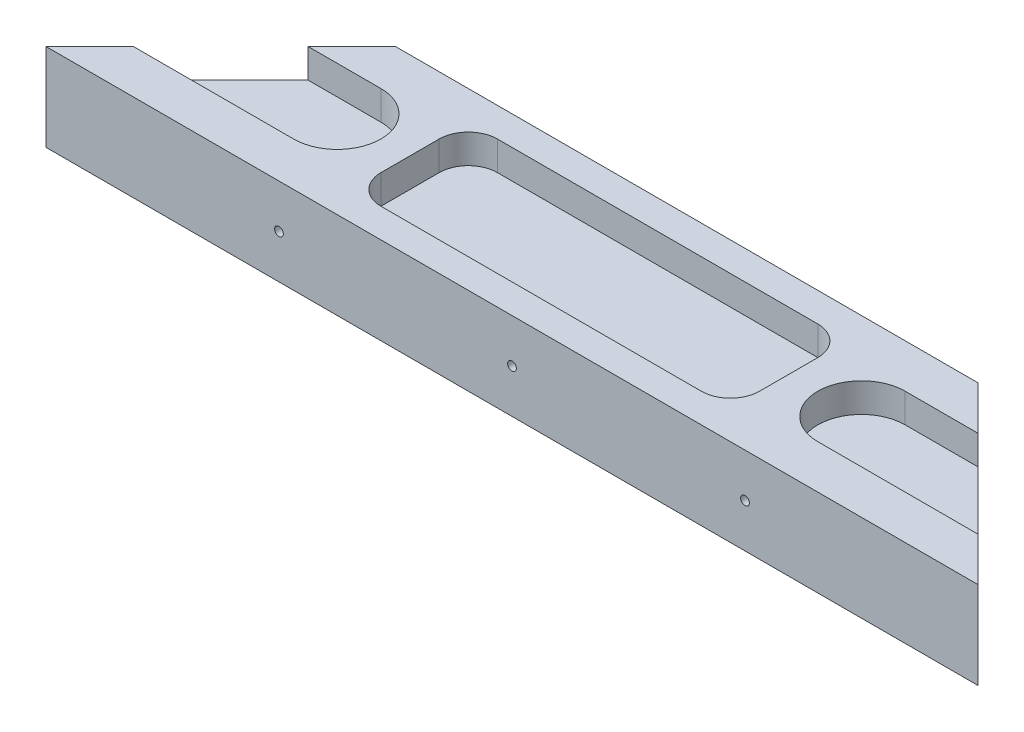
from build123d import *

# Parameters (mm, degrees)
BOSS_EXTRUDE1_DEPTH = 15
CUT_EXTRUDE1_DEPTH  = 5
SKETCH3_R           = 0.75
CUT_EXTRUDE2_DEPTH  = 30
CUT_EXTRUDE3_DEPTH  = 5


with BuildPart() as part:
    # Sketch1 → Boss-Extrude1 (new body)
    with BuildSketch(Plane(origin=(0, 0, 0), x_dir=(1, 0, 0), z_dir=(0, 1, 0))):
        Polygon((0, 0), (160, 0), (130, 30), (30, 30), align=None)
    extrude(amount=BOSS_EXTRUDE1_DEPTH)

    # Sketch2 → Cut-Extrude1 (cut)
    with BuildSketch(Plane(origin=(0, 15, 0), x_dir=(1, 0, 0), z_dir=(0, 1, 0))):
        with BuildLine():
            Line((-5, 22.5), (35, 22.5))
            ThreePointArc((35, 22.5), (42.5, 15), (35, 7.5))
            Line((35, 7.5), (-5, 7.5))
            ThreePointArc((-5, 7.5), (-12.5, 15), (-5, 22.5))
        make_face()
        with BuildLine():
            Line((165, 22.5), (125, 22.5))
            ThreePointArc((125, 22.5), (117.5, 15), (125, 7.5))
            Line((125, 7.5), (165, 7.5))
            ThreePointArc((165, 7.5), (172.5, 15), (165, 22.5))
        make_face()
    extrude(amount=-CUT_EXTRUDE1_DEPTH, mode=Mode.SUBTRACT)

    # Sketch3 → Cut-Extrude2 (cut)
    with BuildSketch(Plane.XY):
        with Locations((80, 7.5)):
            Circle(SKETCH3_R)
        with Locations((40, 7.5)):
            Circle(SKETCH3_R)
        with Locations((120, 7.5)):
            Circle(SKETCH3_R)
    extrude(amount=-CUT_EXTRUDE2_DEPTH, mode=Mode.SUBTRACT)

    # Sketch4 → Cut-Extrude3 (cut)
    with BuildSketch(Plane(origin=(0, 15, 0), x_dir=(1, 0, 0), z_dir=(0, 1, 0))):
        with BuildLine():
            Line((52.5, 25), (107.5, 25))
            ThreePointArc((107.5, 25), (111.035533906, 23.535533906), (112.5, 20))
            Line((112.5, 20), (112.5, 10))
            ThreePointArc((112.5, 10), (111.035533906, 6.464466094), (107.5, 5))
            Line((107.5, 5), (52.5, 5))
            ThreePointArc((52.5, 5), (48.964466094, 6.464466094), (47.5, 10))
            Line((47.5, 10), (47.5, 20))
            ThreePointArc((47.5, 20), (48.964466094, 23.535533906), (52.5, 25))
        make_face()
    extrude(amount=-CUT_EXTRUDE3_DEPTH, mode=Mode.SUBTRACT)


solid = part.part
